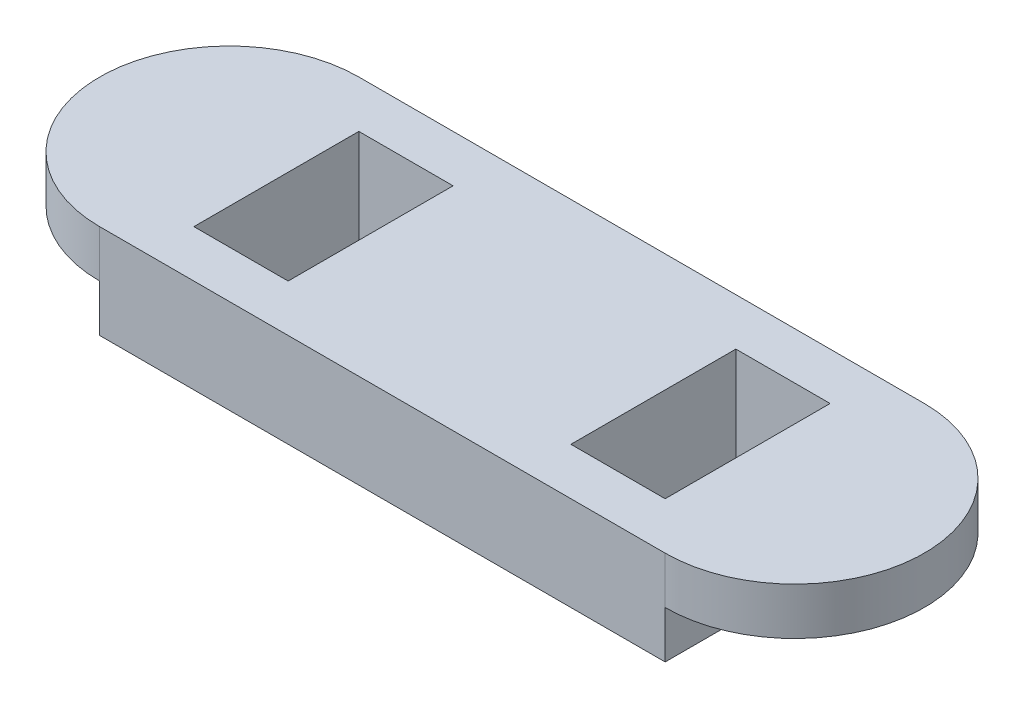
from build123d import *

# Parameters (mm, degrees)
SKETCH2_W           = 120
SKETCH2_H           = 55
BOSS_EXTRUDE1_DEPTH = 20
SKETCH3_W           = 20
SKETCH3_H           = 35
CUT_EXTRUDE1_DEPTH  = 20
BOSS_EXTRUDE2_DEPTH = 10


with BuildPart() as part:
    # Sketch2 → Boss-Extrude1 (new body)
    with BuildSketch(Plane(origin=(0, 0, 0), x_dir=(1, 0, 0), z_dir=(0, 1, 0))):
        Rectangle(SKETCH2_W, SKETCH2_H)
    extrude(amount=BOSS_EXTRUDE1_DEPTH)

    # Sketch3 → Cut-Extrude1 (cut)
    with BuildSketch(Plane(origin=(0, 0, 0), x_dir=(-1, 0, 0), z_dir=(0, -1, 0))):
        with Locations((40, 0)):
            Rectangle(SKETCH3_W, SKETCH3_H)
        with Locations((-40, 0)):
            Rectangle(SKETCH3_W, SKETCH3_H)
    extrude(amount=-CUT_EXTRUDE1_DEPTH, mode=Mode.SUBTRACT)

    # Sketch4 → Boss-Extrude2 (add)
    with BuildSketch(Plane(origin=(0, 20, 0), x_dir=(1, 0, 0), z_dir=(0, 1, 0))):
        with BuildLine():
            ThreePointArc((-60, 27.5), (-87.5, 0), (-60, -27.5))
            Line((-60, -27.5), (-60, 27.5))
        make_face()
        with BuildLine():
            ThreePointArc((60, 27.5), (87.5, 0), (60, -27.5))
            Line((60, -27.5), (60, 27.5))
        make_face()
    extrude(amount=-BOSS_EXTRUDE2_DEPTH)


solid = part.part
